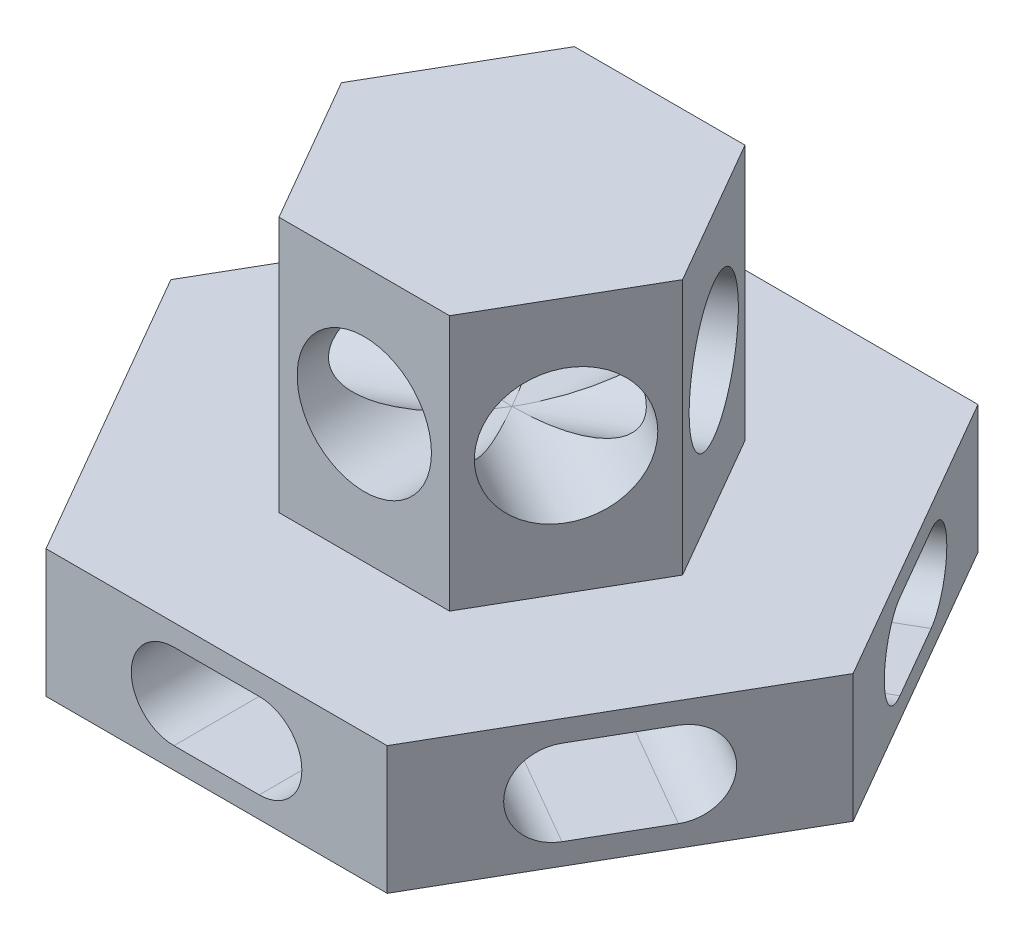
from build123d import *

# Parameters (mm, degrees)
SALIENTE_EXTRUIR1_DEPTH = 30
SALIENTE_EXTRUIR2_DEPTH = 90
CORTAR_EXTRUIR1_DEPTH   = 138.564065
MATRIZC1_COUNT          = 6
CROQUIS4_R              = 15.75
CORTAR_EXTRUIR2_DEPTH   = 103.923048
MATRIZC2_COUNT          = 6


with BuildPart() as part:
    # Croquis1 → Saliente-Extruir1 (new body)
    with BuildSketch(Plane(origin=(0, 0, 0), x_dir=(1, 0, 0), z_dir=(0, 1, 0))):
        Polygon((40, 69.282032303), (-40, 69.282032303), (-80, 0), (-40, -69.282032303), (40, -69.282032303), (80, 0), align=None)
    extrude(amount=SALIENTE_EXTRUIR1_DEPTH)

    # Croquis2 → Saliente-Extruir2 (add)
    with BuildSketch(Plane(origin=(0, 0, 0), x_dir=(1, 0, 0), z_dir=(0, 1, 0))):
        Polygon((20, 34.641016151), (-20, 34.641016151), (-40, 0), (-20, -34.641016151), (20, -34.641016151), (40, 0), align=None)
    extrude(amount=SALIENTE_EXTRUIR2_DEPTH)

    # Croquis3 → Cortar-Extruir1 (cut)
    with BuildSketch(Plane(origin=(60, 0, 34.641016151), x_dir=(0.5, 0, -0.866025404), z_dir=(0.866025404, 0, 0.5))):
        with BuildLine():
            Line((-10, 25), (10, 25))
            ThreePointArc((10, 25), (20, 15), (10, 5))
            Line((10, 5), (-10, 5))
            ThreePointArc((-10, 5), (-20, 15), (-10, 25))
        make_face()
    cortar_extruir1 = extrude(amount=-CORTAR_EXTRUIR1_DEPTH, mode=Mode.SUBTRACT)

    # MatrizC1: Cortar-Extruir1 ×6 about axis
    matrizc1_axis = Axis((0, 0, 0), (0, 1, 0))
    for i in range(1, MATRIZC1_COUNT):
        add(cortar_extruir1.rotate(matrizc1_axis, i * 360 / MATRIZC1_COUNT), mode=Mode.SUBTRACT)

    # Croquis4 → Cortar-Extruir2 (cut)
    with BuildSketch(Plane(origin=(30, 0, -17.320508076), x_dir=(-0.5, 0, -0.866025404), z_dir=(0.866025404, 0, -0.5))):
        with Locations((0, 60)):
            Circle(CROQUIS4_R)
    cortar_extruir2 = extrude(amount=-CORTAR_EXTRUIR2_DEPTH, mode=Mode.SUBTRACT)

    # MatrizC2: Cortar-Extruir2 ×6 about axis
    matrizc2_axis = Axis((0, 90, 0), (0, 1, 0))
    for i in range(1, MATRIZC2_COUNT):
        add(cortar_extruir2.rotate(matrizc2_axis, i * 360 / MATRIZC2_COUNT), mode=Mode.SUBTRACT)


solid = part.part
